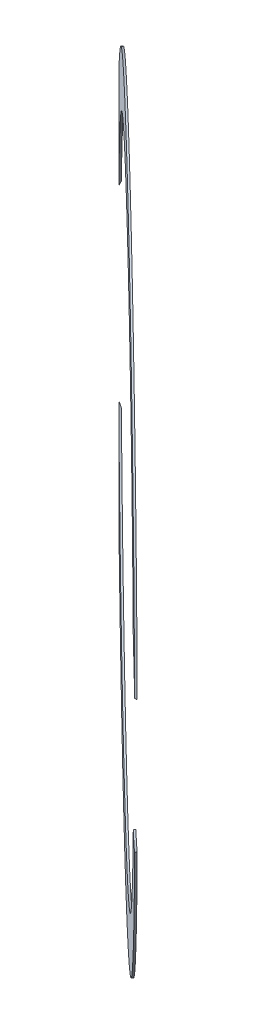
from build123d import *

# Parameters (mm, degrees)
SKETCH2_R               = 298.47899177
SKETCH2_R_2             = 257.20399177
EXTRUDE1_DEPTH          = 1.651
SKETCH3_R               = 76.2
CUT_EXTRUDE1_DEPTH      = 378.598146182
SKETCH4_R               = 381
CUT_EXTRUDE2_DEPTH      = 2.032
CUT_EXTRUDE2_DEPTH_BACK = 38.60972985


with BuildPart() as part:
    # Sketch2 → Extrude1 (new body)
    with BuildSketch(Plane(origin=(-164.227634794, 0, 170.588907734), x_dir=(0.720411288, 0, 0.693547098), z_dir=(-0.693547098, 0, 0.720411288))):
        Circle(SKETCH2_R)
        Circle(SKETCH2_R_2, mode=Mode.SUBTRACT)
    extrude(amount=-EXTRUDE1_DEPTH)

    # Sketch3 → Cut-Extrude1 (cut, through all)
    with BuildSketch(Plane.XY):
        Circle(SKETCH3_R)
    extrude(amount=CUT_EXTRUDE1_DEPTH, mode=Mode.SUBTRACT)

    # Sketch4 → Cut-Extrude2 (cut, two sides)
    with BuildSketch(Plane.XY) as cut_extrude2_sk:
        Circle(SKETCH4_R)
    extrude(amount=CUT_EXTRUDE2_DEPTH, mode=Mode.SUBTRACT)
    extrude(cut_extrude2_sk.sketch, amount=-CUT_EXTRUDE2_DEPTH_BACK, mode=Mode.SUBTRACT)


solid = part.part
